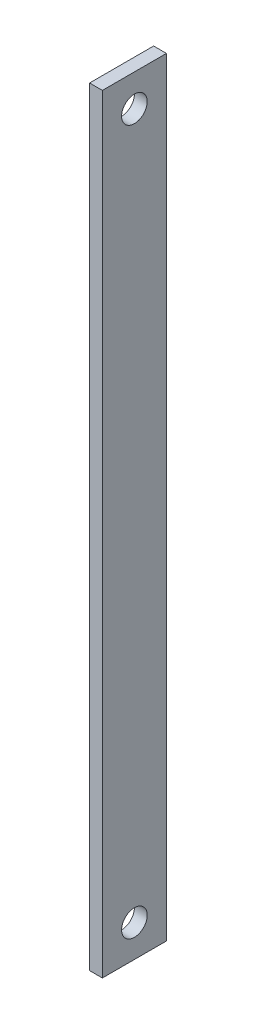
from build123d import *

# Parameters (mm, degrees)
SKETCH1_W           = 10
SKETCH1_H           = 120
SKETCH1_R           = 2
BOSS_EXTRUDE1_DEPTH = 2


with BuildPart() as part:
    # Sketch1 → Boss-Extrude1 (new body)
    with BuildSketch(Plane(origin=(0, 0, 0), x_dir=(0, 0, -1), z_dir=(1, 0, 0))):
        with Locations((5, 60)):
            Rectangle(SKETCH1_W, SKETCH1_H)
        with Locations((5, 115)):
            Circle(SKETCH1_R, mode=Mode.SUBTRACT)
        with Locations((5, 5)):
            Circle(SKETCH1_R, mode=Mode.SUBTRACT)
    extrude(amount=BOSS_EXTRUDE1_DEPTH)


solid = part.part
